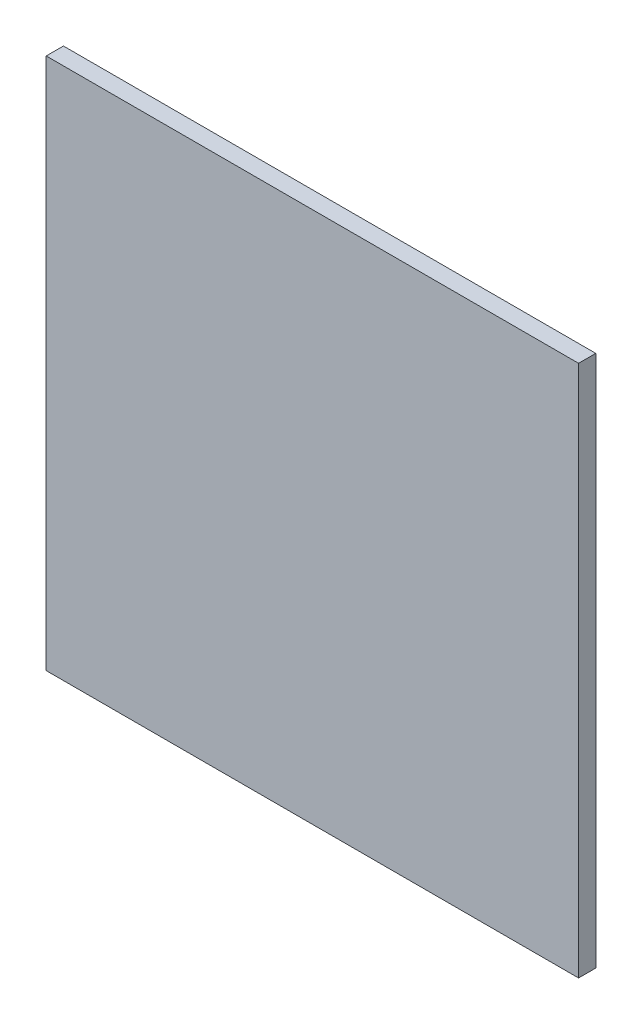
from build123d import *

# Parameters (mm, degrees)
SKETCH1_W           = 368.3
SKETCH1_H           = 368.3
BOSS_EXTRUDE1_DEPTH = 11.90625


with BuildPart() as part:
    # Sketch1 → Boss-Extrude1 (new body)
    with BuildSketch(Plane.XY):
        with Locations((184.15, 184.15)):
            Rectangle(SKETCH1_W, SKETCH1_H)
    extrude(amount=BOSS_EXTRUDE1_DEPTH)


solid = part.part
